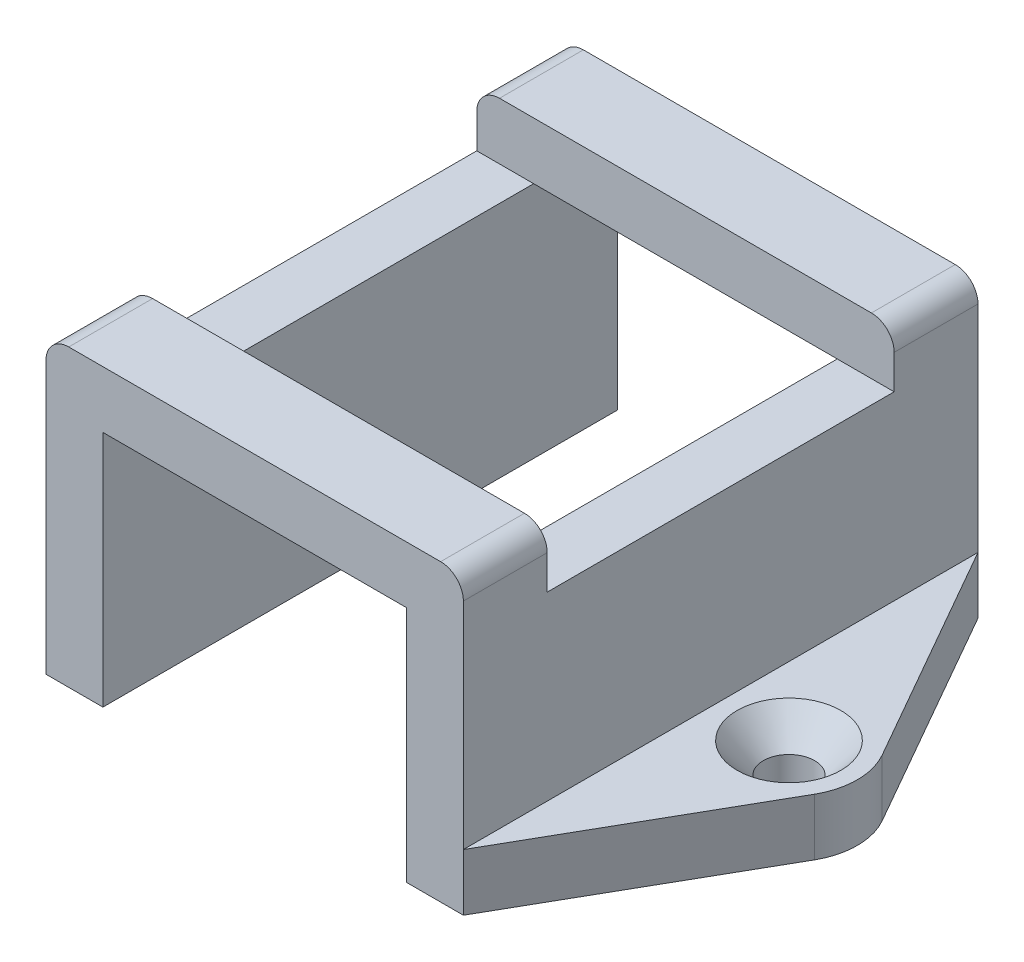
from build123d import *

# Parameters (mm, degrees)
BOSS_EXTRUDE1_DEPTH = 22.606
SKETCH2_W           = 32.636558609
SKETCH2_H           = 30.48
CUT_EXTRUDE1_DEPTH  = 44.22301515
CUT_EXTRUDE2_DEPTH  = 44.22301515
FILLET1_R           = 2


with BuildPart() as part:
    # Sketch1 → Boss-Extrude1 (new, symmetric)
    with BuildSketch(Plane.XY):
        Polygon((0, 20.9042), (13.335, 20.9042), (13.335, 0), (30.335, 0), (30.335, 5), (18.335, 5), (18.335, 25.9042), (0, 25.9042), align=None)
    extrude(amount=BOSS_EXTRUDE1_DEPTH, both=True)

    # Sketch2 → Cut-Extrude1 (cut, through all)
    with BuildSketch(Plane.XZ.offset(-20.9042)):
        with Locations((16.318279305, 0)):
            Rectangle(SKETCH2_W, SKETCH2_H)
    extrude(amount=-CUT_EXTRUDE1_DEPTH, mode=Mode.SUBTRACT)

    # Sketch4 → CSK for _8 Flat Head Socket Cap Screw1 (revolve, cut)
    with BuildSketch(Plane(origin=(24.335, 5, 0), x_dir=(0, 0, 1), z_dir=(1, 0, 0))):
        Polygon((0, 0), (0, 5), (2.2479, 5), (2.2479, 2.658961536), (4.5593, 0), align=None)
    revolve(axis=Axis((24.335, 11.35, 0), (0, -1, 0)), mode=Mode.SUBTRACT)

    # Sketch5 → Cut-Extrude2 (cut, through all)
    with BuildSketch(Plane(origin=(0, 5, 0), x_dir=(1, 0, 0), z_dir=(0, 1, 0))):
        with BuildLine():
            Line((30.335, -22.606), (30.335, 2.1e-08))
            ThreePointArc((30.335, 2.1e-08), (30.134211007, -1.539204892), (29.545282756, -2.975391336))
            Line((29.545282756, -2.975391336), (18.335, -22.606))
            Line((18.335, -22.606), (30.335, -22.606))
        make_face()
        with BuildLine():
            Line((30.335, 22.606), (18.335, 22.606))
            Line((18.335, 22.606), (29.545282756, 2.975391336))
            ThreePointArc((29.545282756, 2.975391336), (30.134211001, 1.539204912), (30.335, 2.1e-08))
            Line((30.335, 2.1e-08), (30.335, 22.606))
        make_face()
    extrude(amount=-CUT_EXTRUDE2_DEPTH, mode=Mode.SUBTRACT)

    # Fillet1
    fillet1_edges = [part.edges().sort_by_distance(p)[0] for p in [
        (18.335, 25.9042, -18.923),
        (18.335, 25.9042, 18.923),
    ]]
    fillet(fillet1_edges, radius=FILLET1_R)

    # Mirror1: part across plane


with BuildPart() as part_1:
    add(part.part)
    add(part.part.mirror(Plane(origin=(0, 0, 0), x_dir=(0, 0, 1), z_dir=(1, 0, 0))))


solid = part_1.part
